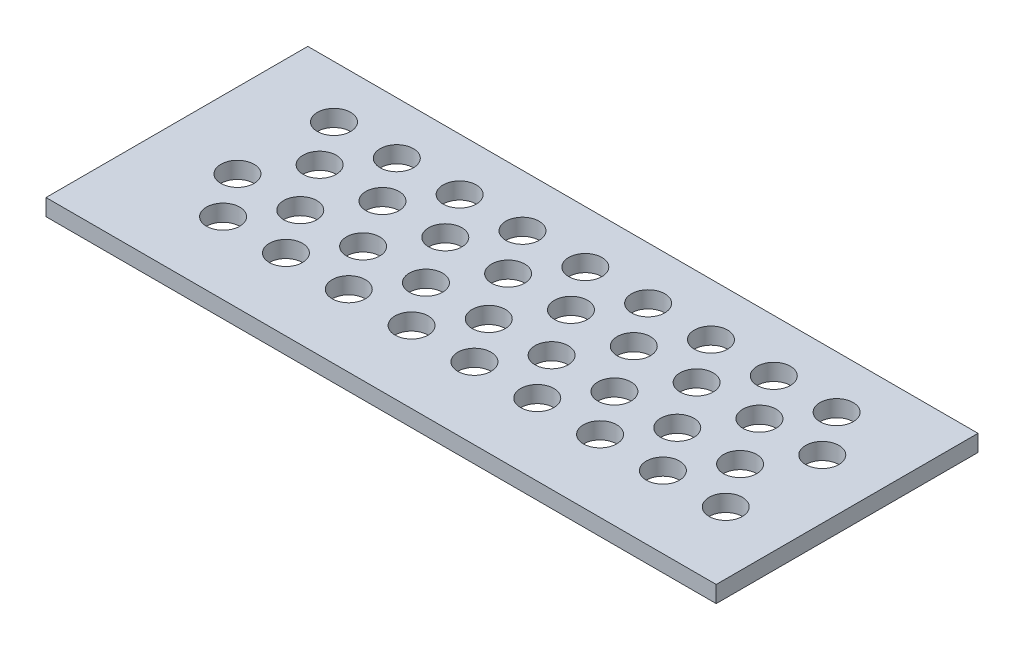
from build123d import *

# Parameters (mm, degrees)
SKETCH1_W           = 128
SKETCH1_H           = 50
BOSS_EXTRUDE1_DEPTH = 3.175
SKETCH2_R           = 3.175
CUT_EXTRUDE1_DEPTH  = 3.175


with BuildPart() as part:
    # Sketch1 → Boss-Extrude1 (new body)
    with BuildSketch(Plane(origin=(0, 0, 0), x_dir=(1, 0, 0), z_dir=(0, 1, 0))):
        with Locations((7.729468599, 5.299516908)):
            Rectangle(SKETCH1_W, SKETCH1_H)
    extrude(amount=BOSS_EXTRUDE1_DEPTH)

    # Sketch2 → Cut-Extrude1 (cut)
    with BuildSketch(Plane(origin=(0, 3.175, 0), x_dir=(1, 0, 0), z_dir=(0, 1, 0))):
        with Locations((-41.270531401, 20.299516908)):
            Circle(SKETCH2_R)
        with Locations((-29.270531401, 20.299516908)):
            Circle(SKETCH2_R)
        with Locations((-17.270531401, 20.299516908)):
            Circle(SKETCH2_R)
        with Locations((-5.270531401, 20.299516908)):
            Circle(SKETCH2_R)
        with Locations((6.729468599, 20.299516908)):
            Circle(SKETCH2_R)
        with Locations((18.729468599, 20.299516908)):
            Circle(SKETCH2_R)
        with Locations((30.729468599, 20.299516908)):
            Circle(SKETCH2_R)
        with Locations((42.729468599, 20.299516908)):
            Circle(SKETCH2_R)
        with Locations((54.729468599, 20.299516908)):
            Circle(SKETCH2_R)
        with Locations((-35.558058134, 11.846734249)):
            Circle(SKETCH2_R)
        with Locations((-23.558058134, 11.846734249)):
            Circle(SKETCH2_R)
        with Locations((-11.558058134, 11.846734249)):
            Circle(SKETCH2_R)
        with Locations((0.441941866, 11.846734249)):
            Circle(SKETCH2_R)
        with Locations((12.441941866, 11.846734249)):
            Circle(SKETCH2_R)
        with Locations((24.441941866, 11.846734249)):
            Circle(SKETCH2_R)
        with Locations((36.441941866, 11.846734249)):
            Circle(SKETCH2_R)
        with Locations((48.441941866, 11.846734249)):
            Circle(SKETCH2_R)
        with Locations((60.441941866, 11.846734249)):
            Circle(SKETCH2_R)
        with Locations((-41.90349241, 2.495409821)):
            Circle(SKETCH2_R)
        with Locations((-29.90349241, 2.495409821)):
            Circle(SKETCH2_R)
        with Locations((-17.90349241, 2.495409821)):
            Circle(SKETCH2_R)
        with Locations((-5.90349241, 2.495409821)):
            Circle(SKETCH2_R)
        with Locations((6.09650759, 2.495409821)):
            Circle(SKETCH2_R)
        with Locations((18.09650759, 2.495409821)):
            Circle(SKETCH2_R)
        with Locations((30.09650759, 2.495409821)):
            Circle(SKETCH2_R)
        with Locations((42.09650759, 2.495409821)):
            Circle(SKETCH2_R)
        with Locations((54.09650759, 2.495409821)):
            Circle(SKETCH2_R)
        with Locations((-36.191019143, -5.957372838)):
            Circle(SKETCH2_R)
        with Locations((-24.191019143, -5.957372838)):
            Circle(SKETCH2_R)
        with Locations((-12.191019143, -5.957372838)):
            Circle(SKETCH2_R)
        with Locations((-0.191019143, -5.957372838)):
            Circle(SKETCH2_R)
        with Locations((11.808980857, -5.957372838)):
            Circle(SKETCH2_R)
        with Locations((23.808980857, -5.957372838)):
            Circle(SKETCH2_R)
        with Locations((35.808980857, -5.957372838)):
            Circle(SKETCH2_R)
        with Locations((47.808980857, -5.957372838)):
            Circle(SKETCH2_R)
        with Locations((59.808980857, -5.957372838)):
            Circle(SKETCH2_R)
    extrude(amount=-CUT_EXTRUDE1_DEPTH, mode=Mode.SUBTRACT)


solid = part.part
